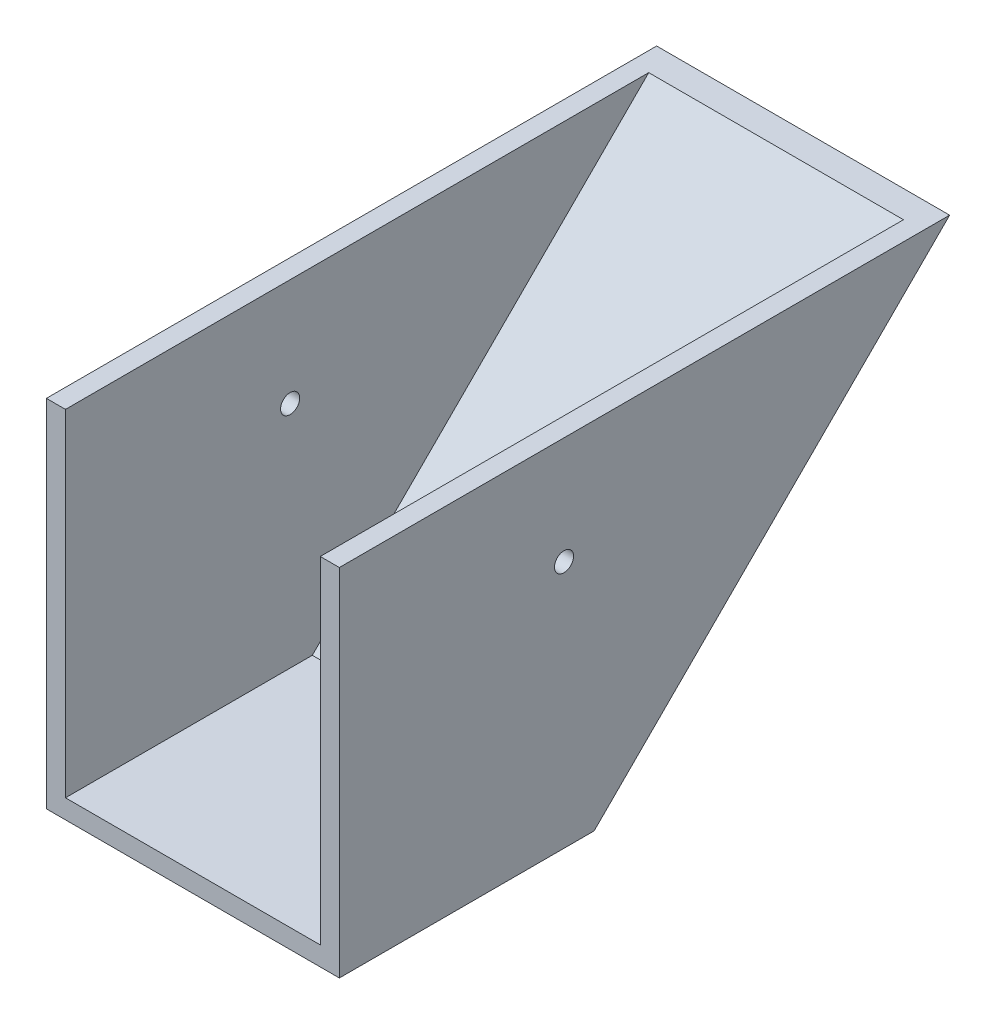
from build123d import *

# Parameters (mm, degrees)
SKETCH2_W           = 292.1
SKETCH2_H           = 635
BOSS_EXTRUDE1_DEPTH = 190.5
CUT_EXTRUDE2_DEPTH  = 381
SHELL1_T            = -19.05
SKETCH5_W           = 292.1
SKETCH5_H           = 635
CUT_EXTRUDE3_DEPTH  = 24.892
SKETCH6_R           = 9.525
CUT_EXTRUDE4_DEPTH  = 514.096
SKETCH10_W          = 292.1
SKETCH10_H          = 610.108
CUT_EXTRUDE7_DEPTH  = 1.693333333


with BuildPart() as part:
    # Sketch2 → Boss-Extrude1 (new body, symmetric)
    with BuildSketch(Plane(origin=(0, 0, 0), x_dir=(1, 0, 0), z_dir=(0, 1, 0))):
        Rectangle(SKETCH2_W, SKETCH2_H)
    extrude(amount=BOSS_EXTRUDE1_DEPTH, both=True)

    # Sketch4 → Cut-Extrude2 (cut)
    with BuildSketch(Plane.ZY.offset(146.05)):
        Polygon((-317.5, 190.5), (63.5, -190.5), (-317.5, -190.5), align=None)
    extrude(amount=-CUT_EXTRUDE2_DEPTH, mode=Mode.SUBTRACT)

    # Shell1
    shell1_openings = [part.faces().sort_by_distance(p)[0] for p in [
        (0, 0, 317.5),
    ]]
    offset(amount=SHELL1_T, openings=shell1_openings, kind=Kind.INTERSECTION)

    # Sketch5 → Cut-Extrude3 (cut)
    with BuildSketch(Plane(origin=(0, 190.5, 0), x_dir=(1, 0, 0), z_dir=(0, 1, 0))):
        Rectangle(SKETCH5_W, SKETCH5_H)
    extrude(amount=-CUT_EXTRUDE3_DEPTH, mode=Mode.SUBTRACT)

    # Sketch6 → Cut-Extrude4 (cut)
    with BuildSketch(Plane.ZY.offset(146.05)):
        with Locations((93.517292524, 56.961208915)):
            Circle(SKETCH6_R)
    extrude(amount=-CUT_EXTRUDE4_DEPTH, mode=Mode.SUBTRACT)

    # Sketch10 → Cut-Extrude7 (cut)
    with BuildSketch(Plane(origin=(0, 165.608, 0), x_dir=(1, 0, 0), z_dir=(0, 1, 0))):
        with Locations((0, -12.446)):
            Rectangle(SKETCH10_W, SKETCH10_H)
    extrude(amount=-CUT_EXTRUDE7_DEPTH, mode=Mode.SUBTRACT)


solid = part.part
